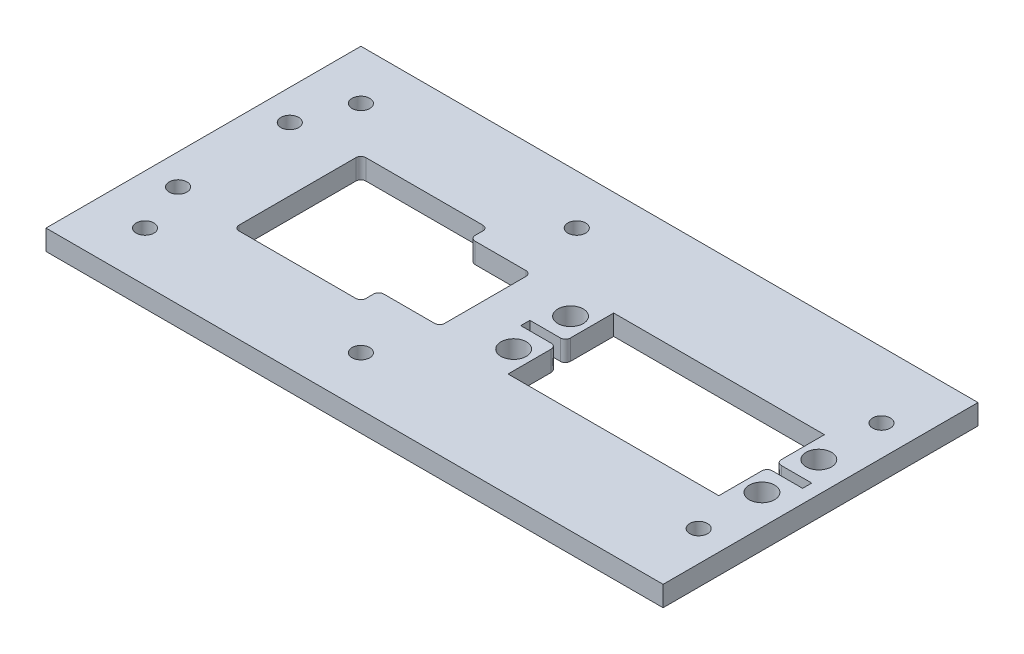
from build123d import *

# Parameters (mm, degrees)
SKETCH1_W           = 121.5
SKETCH1_H           = 62
SKETCH1_W_2         = 25
SKETCH1_H_2         = 25
BOSS_EXTRUDE1_DEPTH = 4
SKETCH2_R           = 2.5
CUT_EXTRUDE1_DEPTH  = 78.575769413
SKETCH3_R           = 1.75
CUT_EXTRUDE2_DEPTH  = 78.575769413
SKETCH4_W           = 12
SKETCH4_H           = 18
CUT_EXTRUDE3_DEPTH  = 78.575769413
FILLET1_R           = 1


with BuildPart() as part:
    # Sketch1 → Boss-Extrude1 (new body)
    with BuildSketch(Plane(origin=(0, 0, 0), x_dir=(1, 0, 0), z_dir=(0, 1, 0))):
        with Locations((10.25, 0)):
            Rectangle(SKETCH1_W, SKETCH1_H)
        with Locations((-19.5, 0)):
            Rectangle(SKETCH1_W_2, SKETCH1_H_2, mode=Mode.SUBTRACT)
    extrude(amount=BOSS_EXTRUDE1_DEPTH)

    # Sketch2 → Cut-Extrude1 (cut, through all)
    with BuildSketch(Plane(origin=(0, 4, 0), x_dir=(1, 0, 0), z_dir=(0, 1, 0))):
        with Locations((16.18, 5.6)):
            Circle(SKETCH2_R)
        with Locations((16.18, -5.6)):
            Circle(SKETCH2_R)
        with Locations((65.06, -5.6)):
            Circle(SKETCH2_R)
        with Locations((65.06, 5.6)):
            Circle(SKETCH2_R)
        Polygon((19.87, -0.9), (12.87, -0.9), (12.87, 0.9), (19.87, 0.9), (19.87, 10.4), (61.37, 10.4), (61.37, 0.9), (68.37, 0.9), (68.37, -0.9), (61.37, -0.9), (61.37, -10.4), (19.87, -10.4), align=None)
    extrude(amount=-CUT_EXTRUDE1_DEPTH, mode=Mode.SUBTRACT)

    # Sketch3 → Cut-Extrude2 (cut, through all)
    with BuildSketch(Plane(origin=(0, 4, 0), x_dir=(1, 0, 0), z_dir=(0, 1, 0))):
        with Locations((1.75, 21.25)):
            Circle(SKETCH3_R)
        with Locations((1.75, -21.25)):
            Circle(SKETCH3_R)
        with Locations((-40.75, -21.25)):
            Circle(SKETCH3_R)
        with Locations((-40.75, 21.25)):
            Circle(SKETCH3_R)
        with Locations((-44.5, 11)):
            Circle(SKETCH3_R)
        with Locations((-44.5, -11)):
            Circle(SKETCH3_R)
        with Locations((65, -18)):
            Circle(SKETCH3_R)
        with Locations((65, 18)):
            Circle(SKETCH3_R)
    extrude(amount=-CUT_EXTRUDE2_DEPTH, mode=Mode.SUBTRACT)

    # Sketch4 → Cut-Extrude3 (cut, through all)
    with BuildSketch(Plane(origin=(0, 4, 0), x_dir=(1, 0, 0), z_dir=(0, 1, 0))):
        with Locations((-1, 0)):
            Rectangle(SKETCH4_W, SKETCH4_H)
    extrude(amount=-CUT_EXTRUDE3_DEPTH, mode=Mode.SUBTRACT)

    # Fillet1
    fillet1_edges = [part.edges().sort_by_distance(p)[0] for p in [
        (-7, 2, -9),
        (-7, 2, -12.5),
        (-32, 2, 12.5),
        (-7, 2, 12.5),
        (-7, 2, 9),
        (5, 2, 9),
        (5, 2, -9),
        (-32, 2, -12.5),
        (61.37, 2, 0.9),
        (61.37, 2, -0.9),
        (19.87, 2, 0.9),
        (19.87, 2, -0.9),
    ]]
    fillet(fillet1_edges, radius=FILLET1_R)


solid = part.part
